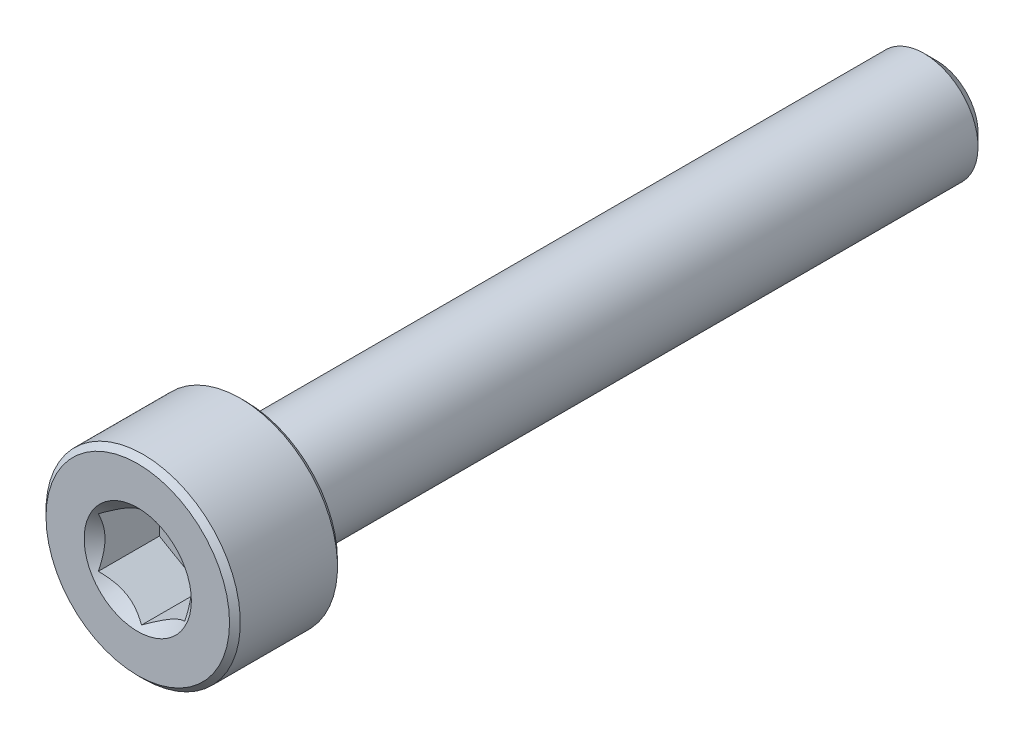
from build123d import *

# Parameters (mm, degrees)
CUT_EXTRUDE1_DEPTH = 1.5
SKETCH4_R          = 1.241303079
CUT_EXTRUDE2_DEPTH = 1.5
CUT_EXTRUDE2_DRAFT = -45


with BuildPart() as part:
    # Sketch2 → Revolve1 (revolve)
    with BuildSketch(Plane(origin=(0, 0, 0), x_dir=(0, 0, -1), z_dir=(1, 0, 0))):
        with BuildLine():
            Line((-9.25, 0), (-9.25, 2.125))
            Line((-9.25, 2.125), (-9.125, 2.25))
            Line((-9.125, 2.25), (-6.875, 2.25))
            Line((-6.875, 2.25), (-6.75, 2.125))
            Line((-6.75, 2.125), (-6.75, 1.375))
            ThreePointArc((-6.75, 1.375), (-6.713388348, 1.286611652), (-6.625, 1.25))
            Line((-6.625, 1.25), (8.957716426, 1.25))
            Line((8.957716426, 1.25), (9.25, 0.957716426))
            Line((9.25, 0.957716426), (9.25, 0))
            Line((9.25, 0), (-9.25, 0))
        make_face()
    revolve(axis=Axis((0, 0, -9.25), (0, 0, 1)))

    # Sketch3 → Cut-Extrude1 (cut)
    with BuildSketch(Plane.XY.offset(9.25)):
        Polygon((1, -0.577350269), (1, 0.577350269), (0, 1.154700538), (-1, 0.577350269), (-1, -0.577350269), (0, -1.154700538), align=None)
    extrude(amount=-CUT_EXTRUDE1_DEPTH, mode=Mode.SUBTRACT)


with BuildPart() as cut_extrude2_tool:
    # Sketch4 → Cut-Extrude2 (with draft: the straight prism first)
    with BuildSketch(Plane.XY.offset(9.25)):
        Circle(SKETCH4_R)
    extrude(amount=-CUT_EXTRUDE2_DEPTH)
    # Cut-Extrude2: the draft: its side faces are tilted about the plane it starts from
    cut_extrude2_sides = [cut_extrude2_tool.faces().sort_by_distance(p)[0] for p in [
        (-1.241303079, 0, 8.5),
    ]]
    draft(cut_extrude2_sides, Plane.XY.offset(9.25), CUT_EXTRUDE2_DRAFT)


with BuildPart() as part_1:
    add(part.part)

    # Cut-Extrude2: cut by cut_extrude2_tool
    add(cut_extrude2_tool.part, mode=Mode.SUBTRACT)


solid = part_1.part
